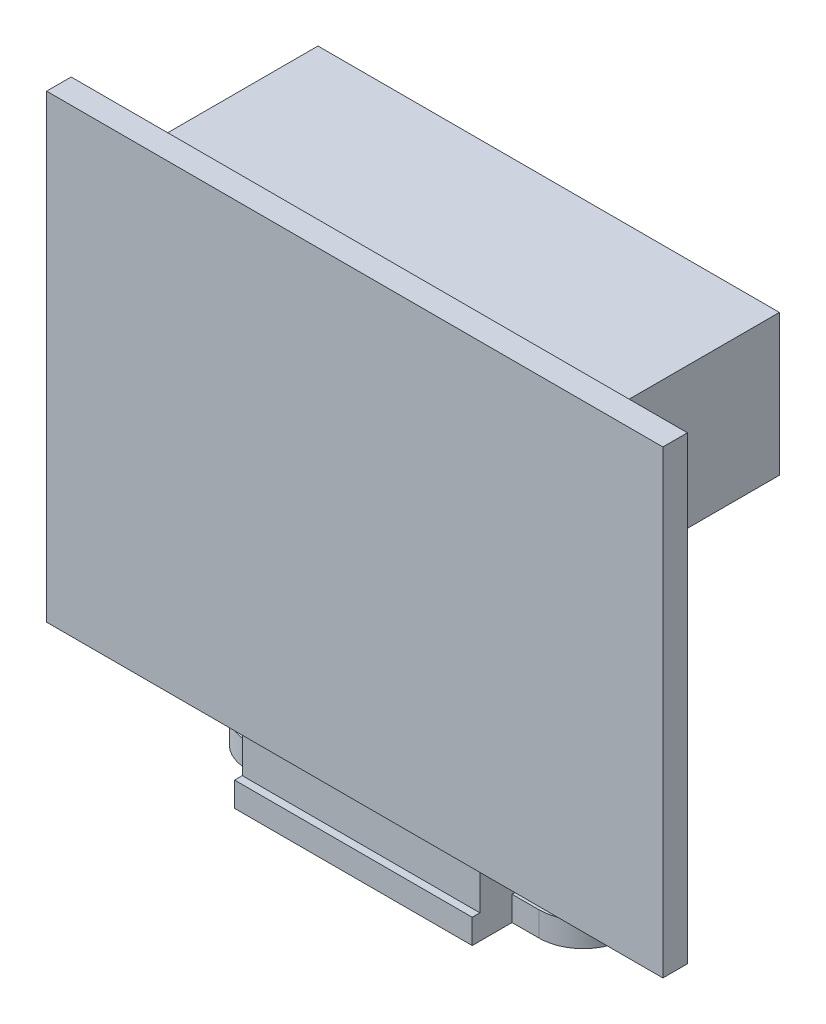
from build123d import *

# Parameters (mm, degrees)
SKETCH1_W           = 15.5
SKETCH1_H           = 11
BOSS_EXTRUDE1_DEPTH = 1.6
BOSS_EXTRUDE2_DEPTH = 1.6
SKETCH3_W           = 15.5
SKETCH3_H           = 2.7
BOSS_EXTRUDE3_DEPTH = 2.7
SKETCH4_W           = 40.2
SKETCH4_H           = 1.6
BOSS_EXTRUDE4_DEPTH = 30
SKETCH5_W           = 30.1
SKETCH5_H           = 9.2
BOSS_EXTRUDE5_DEPTH = 12.1
SKETCH6_R           = 2
CUT_EXTRUDE1_DEPTH  = 2
LPATTERN1_COUNT     = 6
LPATTERN1_PITCH     = 5


with BuildPart() as part:
    # Sketch1 → Boss-Extrude1 (new body)
    with BuildSketch(Plane(origin=(0, 0, 0), x_dir=(1, 0, 0), z_dir=(0, 1, 0))):
        with Locations((7.75, -5.5)):
            Rectangle(SKETCH1_W, SKETCH1_H)
    extrude(amount=BOSS_EXTRUDE1_DEPTH)

    # Sketch2 → Boss-Extrude2 (add, through all)
    with BuildSketch(Plane(origin=(0, 1.6, 0), x_dir=(1, 0, 0), z_dir=(0, 1, 0))):
        with BuildLine():
            Line((-1.75, -4), (-1.75, -2.6))
            ThreePointArc((-1.75, -2.6), (-4.65, -5.5), (-1.75, -8.4))
            Line((-1.75, -8.4), (-1.75, -7))
            ThreePointArc((-1.75, -7), (-3.25, -5.5), (-1.75, -4))
        make_face()
        with BuildLine():
            ThreePointArc((0, -3.187533784), (-0.827002716, -2.750804479), (-1.75, -2.6))
            Line((-1.75, -2.6), (-1.75, -4))
            ThreePointArc((-1.75, -4), (-0.689339828, -4.439339828), (-0.25, -5.5))
            ThreePointArc((-0.25, -5.5), (-0.689339828, -6.560660172), (-1.75, -7))
            Line((-1.75, -7), (-1.75, -8.4))
            ThreePointArc((-1.75, -8.4), (-0.827002716, -8.249195521), (0, -7.812466216))
            Line((0, -7.812466216), (0, -3.187533784))
        make_face()
        with BuildLine():
            Line((0, -2.6), (-1.75, -2.6))
            ThreePointArc((-1.75, -2.6), (-0.827002716, -2.750804479), (0, -3.187533784))
            Line((0, -3.187533784), (0, -2.6))
        make_face()
        with BuildLine():
            ThreePointArc((0, -7.812466216), (-0.827002716, -8.249195521), (-1.75, -8.4))
            Line((-1.75, -8.4), (0, -8.4))
            Line((0, -8.4), (0, -7.812466216))
        make_face()
        with BuildLine():
            ThreePointArc((20.15, -5.5), (19.300609665, -3.449390335), (17.25, -2.6))
            Line((17.25, -2.6), (17.25, -4))
            ThreePointArc((17.25, -4), (18.310660172, -4.439339828), (18.75, -5.5))
            ThreePointArc((18.75, -5.5), (18.310660172, -6.560660172), (17.25, -7))
            Line((17.25, -7), (17.25, -8.4))
            ThreePointArc((17.25, -8.4), (19.300609665, -7.550609665), (20.15, -5.5))
        make_face()
        with BuildLine():
            Line((17.25, -4), (17.25, -2.6))
            ThreePointArc((17.25, -2.6), (16.327002716, -2.750804479), (15.5, -3.187533784))
            Line((15.5, -3.187533784), (15.5, -7.812466216))
            ThreePointArc((15.5, -7.812466216), (16.327002716, -8.249195521), (17.25, -8.4))
            Line((17.25, -8.4), (17.25, -7))
            ThreePointArc((17.25, -7), (15.75, -5.5), (17.25, -4))
        make_face()
        with BuildLine():
            Line((17.25, -2.6), (15.5, -2.6))
            Line((15.5, -2.6), (15.5, -3.187533784))
            ThreePointArc((15.5, -3.187533784), (16.327002716, -2.750804479), (17.25, -2.6))
        make_face()
        with BuildLine():
            Line((15.5, -7.812466216), (15.5, -8.4))
            Line((15.5, -8.4), (17.25, -8.4))
            ThreePointArc((17.25, -8.4), (16.327002716, -8.249195521), (15.5, -7.812466216))
        make_face()
    extrude(amount=-BOSS_EXTRUDE2_DEPTH)

    # Sketch3 → Boss-Extrude3 (add)
    with BuildSketch(Plane(origin=(0, 1.6, 0), x_dir=(1, 0, 0), z_dir=(0, 1, 0))):
        with Locations((7.75, -9.15)):
            Rectangle(SKETCH3_W, SKETCH3_H)
    extrude(amount=BOSS_EXTRUDE3_DEPTH)

    # Sketch4 → Boss-Extrude4 (add)
    with BuildSketch(Plane(origin=(0, 4.3, 0), x_dir=(1, 0, 0), z_dir=(0, 1, 0))):
        with Locations((7.75, -10.112281479)):
            Rectangle(SKETCH4_W, SKETCH4_H)
    extrude(amount=BOSS_EXTRUDE4_DEPTH)

    # Sketch5 → Boss-Extrude5 (add)
    with BuildSketch(Plane(origin=(0, 0, 9.312281479), x_dir=(-1, 0, 0), z_dir=(0, 0, -1))):
        with Locations((-6.7, 27.4)):
            Rectangle(SKETCH5_W, SKETCH5_H)
    extrude(amount=BOSS_EXTRUDE5_DEPTH)

    # Sketch6 → Cut-Extrude1 (cut)
    with BuildSketch(Plane(origin=(0, 0, -2.787718521), x_dir=(-1, 0, 0), z_dir=(0, 0, -1))):
        with Locations((-19.35, 27.8)):
            Circle(SKETCH6_R)
    cut_extrude1 = extrude(amount=-CUT_EXTRUDE1_DEPTH, mode=Mode.SUBTRACT)

    # LPattern1: Cut-Extrude1 ×6
    with Locations(*[(-i * LPATTERN1_PITCH, 0, 0) for i in range(1, LPATTERN1_COUNT)]):
        add(cut_extrude1, mode=Mode.SUBTRACT)


solid = part.part
